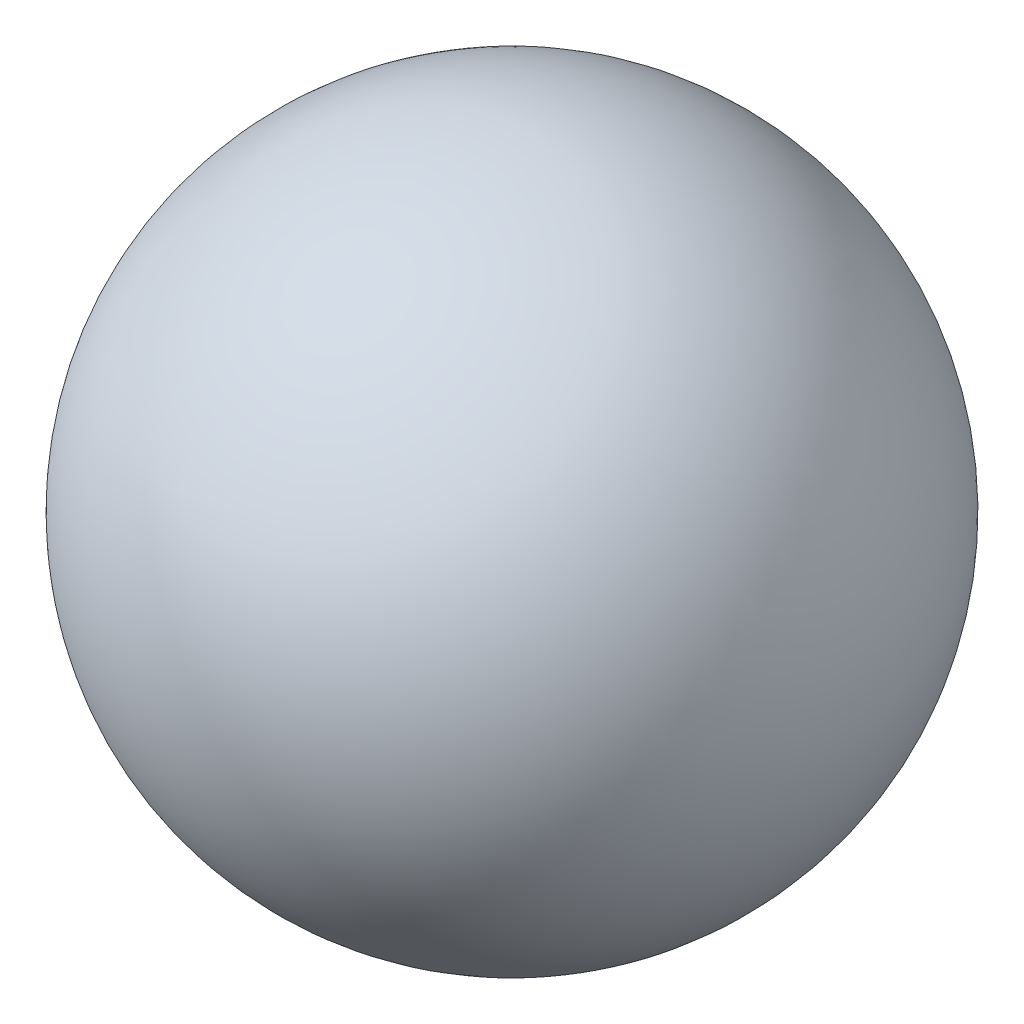
from build123d import *


with BuildPart() as part:
    # Sketch1 one side → Revolve1 (revolve)
    with BuildSketch(Plane.XY):
        with BuildLine():
            ThreePointArc((15.518886296, -87.534988251), (68.127964125, -57.112087198), (88.9, 0))
            ThreePointArc((88.9, 0), (57.112087198, 68.127964125), (-15.518886296, 87.534988251))
            Line((-15.518886296, 87.534988251), (15.518886296, -87.534988251))
        make_face()
    revolve(axis=Axis((-15.518886296, 87.534988251, 0), (0.17456565, -0.984645537, 0)))


solid = part.part
